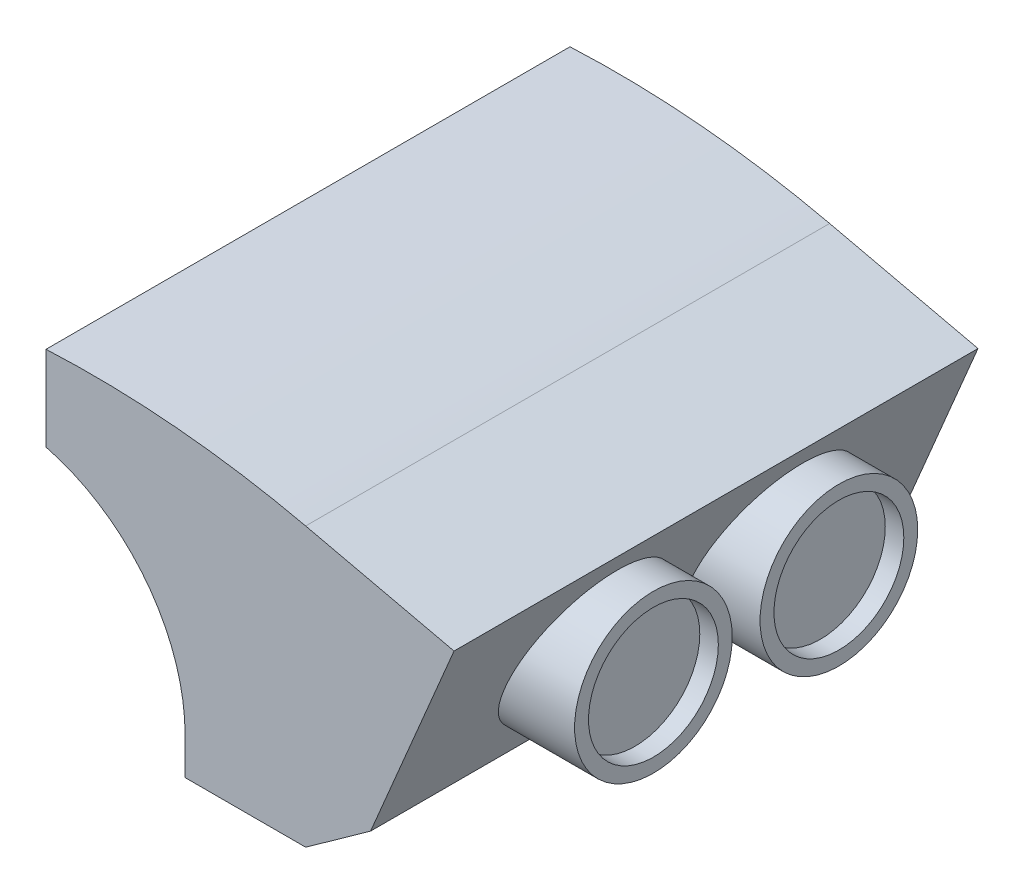
from build123d import *

# Parameters (mm, degrees)
SKETCH1_W           = 28
SKETCH1_H           = 56.5
BOSS_EXTRUDE1_DEPTH = 30
CUT_EXTRUDE2_DEPTH  = 56.5
SHELL1_T            = -1
BOSS_EXTRUDE3_DEPTH = 2.5
SKETCH4_R           = 0.35
CUT_EXTRUDE1_DEPTH  = 5
BOSS_EXTRUDE4_DEPTH = 56.5
BOSS_EXTRUDE5_START = -11.087816
SKETCH7_R           = 8.5
BOSS_EXTRUDE5_DEPTH = 11.087816
SKETCH8_R           = 7
CUT_EXTRUDE3_DEPTH  = 2
LPATTERN1_COUNT     = 2
LPATTERN1_PITCH     = 20


with BuildPart() as part:
    # Sketch1 → Boss-Extrude1 (new body)
    with BuildSketch(Plane(origin=(0, 0, 0), x_dir=(1, 0, 0), z_dir=(0, 1, 0))):
        Rectangle(SKETCH1_W, SKETCH1_H)
    extrude(amount=-BOSS_EXTRUDE1_DEPTH)

    # Sketch5 → Cut-Extrude2 (cut)
    with BuildSketch(Plane(origin=(0, 0, -28.25), x_dir=(-1, 0, 0), z_dir=(0, 0, -1))):
        with BuildLine():
            Line((-1, -30), (-1, -26))
            ThreePointArc((-1, -26), (3.188611699, -13.752551286), (14, -6.635083269))
            Line((14, -6.635083269), (14, -30))
            Line((14, -30), (-1, -30))
        make_face()
    extrude(amount=-CUT_EXTRUDE2_DEPTH, mode=Mode.SUBTRACT)

    # Shell1
    shell1_openings = [part.faces().sort_by_distance(p)[0] for p in [
        (7.5, -30, 0),
        (0.885231383, -15.011682153, -28.25),
        (-4.84430585, -15.03504646, 0),
        (1, -28, 0),
    ]]
    offset(amount=SHELL1_T, openings=shell1_openings, kind=Kind.INTERSECTION)

    # Sketch3 → Boss-Extrude3 (add, symmetric)
    with BuildSketch(Plane.XY.offset(-20)):
        with BuildLine():
            Line((-14, -1), (-15, -1))
            ThreePointArc((-15, -1), (-15.5, -1.5), (-15, -2))
            Line((-15, -2), (-14, -2))
            Line((-14, -2), (-12.5, -1))
            Line((-12.5, -1), (-14, -1))
        make_face()
    boss_extrude3 = extrude(amount=BOSS_EXTRUDE3_DEPTH, both=True)

    # Sketch4 → Cut-Extrude1 (cut)
    with BuildSketch(Plane(origin=(0, 0, -22.5), x_dir=(-1, 0, 0), z_dir=(0, 0, -1))):
        with Locations((15, -1.5)):
            Circle(SKETCH4_R)
    cut_extrude1 = extrude(amount=-CUT_EXTRUDE1_DEPTH, mode=Mode.SUBTRACT)

    # Mirror1: Boss-Extrude3, Cut-Extrude1 across plane
    add(boss_extrude3.mirror(Plane.XY))
    add(cut_extrude1.mirror(Plane.XY), mode=Mode.SUBTRACT)

    # Sketch6 → Boss-Extrude4 (add)
    with BuildSketch(Plane(origin=(0, 0, -28.25), x_dir=(-1, 0, 0), z_dir=(0, 0, -1))):
        Polygon((-30, -3.677832944), (-21, -25), (-14, -30), (-14, 0), align=None)
        with BuildLine():
            Line((14, 0), (14, 2.5))
            ThreePointArc((14, 2.5), (-0.085690207, 2.209730318), (-14, 0))
            Line((-14, 0), (14, 0))
        make_face()
    extrude(amount=-BOSS_EXTRUDE4_DEPTH)

    # Sketch7 → Boss-Extrude5 (add)
    with BuildSketch(Plane(origin=(33, 0, 0), x_dir=(0, 0, -1), z_dir=(1, 0, 0)).offset(BOSS_EXTRUDE5_START)):
        with Locations((10.25, -14.338916472)):
            Circle(SKETCH7_R)
    boss_extrude5 = extrude(amount=BOSS_EXTRUDE5_DEPTH)

    # Sketch8 → Cut-Extrude3 (cut)
    with BuildSketch(Plane(origin=(33, 0, 0), x_dir=(0, 0, -1), z_dir=(1, 0, 0))):
        with Locations((10.25, -14.338916472)):
            Circle(SKETCH8_R)
    cut_extrude3 = extrude(amount=-CUT_EXTRUDE3_DEPTH, mode=Mode.SUBTRACT)

    # LPattern1: Boss-Extrude5, Cut-Extrude3 ×2
    with Locations(*[(0, 0, i * LPATTERN1_PITCH) for i in range(1, LPATTERN1_COUNT)]):
        add(boss_extrude5)
        add(cut_extrude3, mode=Mode.SUBTRACT)


solid = part.part
